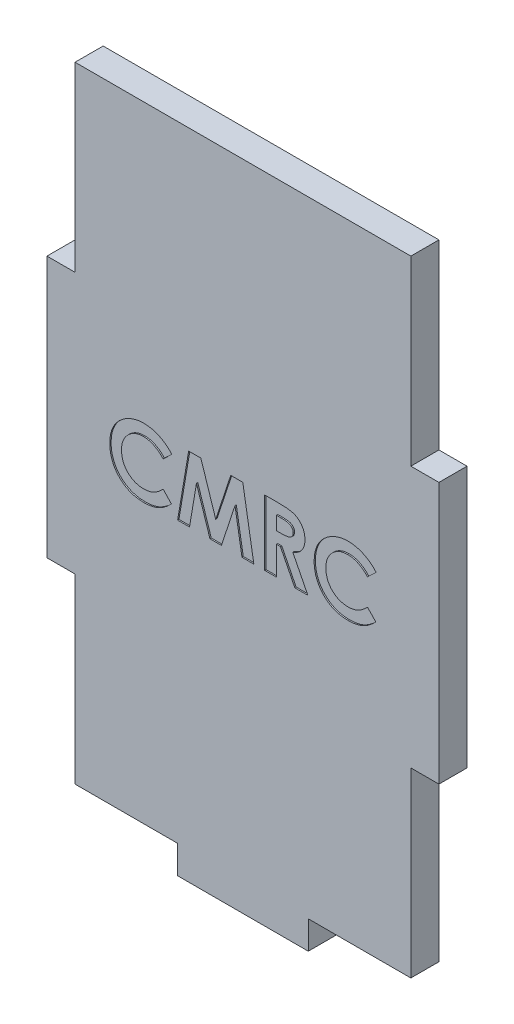
from build123d import *

# Parameters (mm, degrees)
BOSS_EXTRUDE1_DEPTH = 2.7305
CUT_EXTRUDE1_DEPTH  = 0.254


with BuildPart() as part:
    # Sketch1 → Boss-Extrude1 (new, symmetric)
    with BuildSketch(Plane.XY):
        Polygon((-32.639, -25.4), (-32.639, -60.7695), (-12.7, -60.7695), (-12.7, -66.2305), (12.7, -66.2305), (12.7, -60.7695), (32.639, -60.7695), (32.639, -25.4), (38.1, -25.4), (38.1, 25.4), (32.639, 25.4), (32.639, 60.7695), (-32.639, 60.7695), (-32.639, 25.4), (-38.1, 25.4), (-38.1, -25.4), align=None)
    extrude(amount=BOSS_EXTRUDE1_DEPTH, both=True)

    # Sketch2 → Cut-Extrude1 (cut)
    with BuildSketch(Plane.XY.offset(2.7305)):
        with BuildLine():
            Line((-13.83974359, 4.146834936), (-15.511197917, 2.549158654))
            add(Edge.make_bspline(
                [(-15.511197917, 2.549158654), (-15.65298429, 2.695766001), (-15.929937496, 2.982136081), (-16.376213337, 3.36126483), (-16.840323963, 3.677217344), (-17.313241027, 3.94331054), (-17.803470937, 4.144629007), (-18.3053453, 4.291333165), (-18.822068731, 4.380773146), (-19.171767275, 4.391006662), (-19.34765625, 4.396153846)],
                knots=[0, 0, 0, 0, 1.115251505, 2.178435587, 3.19620269, 4.182487026, 5.141301733, 6.088180966, 7.038406374, 8, 8, 8, 8], degree=3))
            add(Edge.make_bspline(
                [(-19.34765625, 4.396153846), (-19.494544919, 4.392087391), (-19.784413523, 4.384062689), (-20.210016594, 4.325233713), (-20.617127927, 4.225192477), (-21.007141129, 4.087317123), (-21.378908569, 3.908913733), (-21.733209703, 3.690120387), (-22.069171018, 3.432913099), (-22.382354658, 3.138622671), (-22.668844045, 2.817088264), (-22.921975661, 2.474011819), (-23.134013993, 2.110179305), (-23.308030404, 1.729275349), (-23.443582461, 1.329536941), (-23.54038366, 0.911233199), (-23.596370887, 0.473865956), (-23.604727356, 0.176546964), (-23.608974359, 0.025440705)],
                knots=[0, 0, 0, 0, 1.035432265, 2.043311493, 3.022114605, 3.98653278, 4.95457646, 5.923598177, 6.917315552, 7.932509744, 8.948865224, 9.949768934, 10.933144597, 11.912367597, 12.897413939, 13.903909035, 14.934704909, 16, 16, 16, 16], degree=3))
            add(Edge.make_bspline(
                [(-23.608974359, 0.025440705), (-23.607750421, -0.08061624), (-23.605338014, -0.289656657), (-23.578929956, -0.598885451), (-23.536406755, -0.898910486), (-23.474865149, -1.189277305), (-23.397906764, -1.470237542), (-23.307617056, -1.744215026), (-23.194349945, -2.007424006), (-23.068621744, -2.262921482), (-22.922401294, -2.503735887), (-22.764748675, -2.733372409), (-22.593800149, -2.95070539), (-22.408448472, -3.154846369), (-22.206085051, -3.342605078), (-21.99194023, -3.519627645), (-21.762401684, -3.681482596), (-21.522237509, -3.832231859), (-21.269372991, -3.963189027), (-21.01066893, -4.08181092), (-20.742202851, -4.178149534), (-20.46724349, -4.255807246), (-20.186773454, -4.321843532), (-19.898049487, -4.362504103), (-19.603574464, -4.393295877), (-19.404558775, -4.395197089), (-19.304407051, -4.396153846)],
                knots=[0, 0, 0, 0, 1.103660481, 2.175337485, 3.227646561, 4.255952547, 5.262355991, 6.258840057, 7.255597736, 8.242457506, 9.22035537, 10.185017736, 11.140346927, 12.096287581, 13.051739095, 14.01125915, 14.986044842, 15.97314143, 16.960198552, 17.947847494, 18.933482797, 19.925264591, 20.920966487, 21.929612487, 22.958107872, 24, 24, 24, 24], degree=3))
            add(Edge.make_bspline(
                [(-19.304407051, -4.396153846), (-19.134532516, -4.391240173), (-18.800773227, -4.381586083), (-18.31093348, -4.306092468), (-17.844165002, -4.181909743), (-17.471219221, -4.035257161), (-17.179026053, -3.890435832), (-16.956583714, -3.756483235), (-16.726560998, -3.606642547), (-16.492778386, -3.43525862), (-16.252606287, -3.244388129), (-16.010284293, -3.029850654), (-15.759608917, -2.798710606), (-15.595393964, -2.633741413), (-15.511197917, -2.549158654)],
                knots=[0, 0, 0, 0, 1.404581149, 2.759636711, 4.088442092, 5.392261763, 6.066678138, 6.783632037, 7.538459478, 8.336747902, 9.180226004, 10.074962426, 11.012997595, 12, 12, 12, 12], degree=3))
            Line((-15.511197917, -2.549158654), (-13.890625, -4.251141827))
            add(Edge.make_bspline(
                [(-13.890625, -4.251141827), (-14.004542553, -4.361125648), (-14.226885255, -4.575790546), (-14.562283048, -4.880594671), (-14.89725873, -5.15449506), (-15.223719986, -5.407433098), (-15.547014591, -5.632040086), (-15.867108262, -5.828540341), (-16.180377397, -6.001903638), (-16.493327131, -6.149206291), (-16.807904798, -6.274281543), (-17.13156825, -6.381963125), (-17.465306956, -6.47305787), (-17.81115924, -6.546559365), (-18.165899202, -6.605497641), (-18.532846737, -6.645280637), (-18.909675217, -6.672025422), (-19.165283813, -6.674428662), (-19.294230769, -6.675641026)],
                knots=[0, 0, 0, 0, 1.244526981, 2.429050516, 3.560637417, 4.644440555, 5.67424972, 6.652764056, 7.595344123, 8.486817594, 9.369275933, 10.254498637, 11.166417451, 12.086725134, 13.032340136, 13.991389299, 14.986715468, 16, 16, 16, 16], degree=3))
            add(Edge.make_bspline(
                [(-19.294230769, -6.675641026), (-19.531090356, -6.669603002), (-19.994558727, -6.657788269), (-20.673759541, -6.570249097), (-21.318982082, -6.423491216), (-21.931796056, -6.215935093), (-22.512006602, -5.950791873), (-23.059465285, -5.625738736), (-23.573289724, -5.241639296), (-24.049329227, -4.802995572), (-24.479929613, -4.318550403), (-24.860530489, -3.798389194), (-25.175363547, -3.239955544), (-25.43677622, -2.651499301), (-25.641197492, -2.030335111), (-25.785075412, -1.375791064), (-25.873803875, -0.688499162), (-25.883510895, -0.21906295), (-25.888461538, 0.020352564)],
                knots=[0, 0, 0, 0, 1.078019885, 2.10938526, 3.111377082, 4.085535484, 5.04941344, 6.010039228, 6.978205633, 7.964457913, 8.951525778, 9.924444315, 10.892603023, 11.863865945, 12.85144698, 13.863884204, 14.910567087, 16, 16, 16, 16], degree=3))
            add(Edge.make_bspline(
                [(-25.888461538, 0.020352564), (-25.886369637, 0.176497319), (-25.882223998, 0.485938061), (-25.838652957, 0.941769345), (-25.777912391, 1.38612331), (-25.681553007, 1.814386091), (-25.565401274, 2.232327176), (-25.420951332, 2.635404036), (-25.24843389, 3.024775152), (-25.053409589, 3.401092356), (-24.832780549, 3.761890367), (-24.586313691, 4.104069362), (-24.320354033, 4.430270898), (-24.028510997, 4.736167307), (-23.715025445, 5.02444442), (-23.378482027, 5.293540007), (-23.020904881, 5.547313202), (-22.641326181, 5.779219811), (-22.247120128, 5.988991665), (-21.843258699, 6.1740194), (-21.430734134, 6.328659977), (-21.011290625, 6.456928632), (-20.583156027, 6.552672113), (-20.149386257, 6.625146839), (-19.706290455, 6.665660675), (-19.408790011, 6.672293048), (-19.258613782, 6.675641026)],
                knots=[0, 0, 0, 0, 1.071919942, 2.124283339, 3.142214191, 4.149696895, 5.136002878, 6.119640489, 7.086990633, 8.058538607, 9.028339693, 9.988281803, 10.952401235, 11.916291999, 12.888973767, 13.874849856, 14.873389453, 15.898127285, 16.927174885, 17.938320013, 18.946391617, 19.950418109, 20.947802303, 21.956882652, 22.968648068, 24, 24, 24, 24], degree=3))
            add(Edge.make_bspline(
                [(-19.258613782, 6.675641026), (-19.130498061, 6.673721881), (-18.875598665, 6.669903546), (-18.496010691, 6.638073571), (-18.119458484, 6.588084917), (-17.747290216, 6.512662682), (-17.37684376, 6.423126959), (-17.012987197, 6.305892281), (-16.649980492, 6.175212138), (-16.293516868, 6.019010711), (-15.943098753, 5.848502744), (-15.606935243, 5.655055263), (-15.279382184, 5.45057281), (-14.967697955, 5.222953218), (-14.66604404, 4.980452672), (-14.375997813, 4.721939772), (-14.100104599, 4.443104348), (-13.926969337, 4.246090662), (-13.83974359, 4.146834936)],
                knots=[0, 0, 0, 0, 0.996412454, 1.982464992, 2.961075852, 3.949442424, 4.934965278, 5.923860011, 6.921385422, 7.934793307, 8.949617135, 9.951082467, 10.950285876, 11.951772932, 12.951063433, 13.960125323, 14.972308753, 16, 16, 16, 16], degree=3))
        make_face()
        Polygon((-10.555348558, 6.35), (-8.189362981, 6.35), (-5.291666667, -2.508453526), (-2.373617788, 6.35), (-0.030528846, 6.35), (2.116666667, -6.35), (-0.190805288, -6.35), (-1.546794872, 1.671454327), (-4.187540064, -6.35), (-6.411057692, -6.35), (-9.036538462, 1.671454327), (-10.389983974, -6.35), (-12.7, -6.35), align=None)
        with BuildLine():
            Line((4.233333333, 6.35), (6.889342949, 6.35))
            add(Edge.make_bspline(
                [(6.889342949, 6.35), (7.064904376, 6.349376858), (7.402558453, 6.34817838), (7.88943719, 6.329269568), (8.336702267, 6.302956405), (8.7450159, 6.262801821), (9.114203406, 6.209561695), (9.444634796, 6.146800397), (9.736300414, 6.075270442), (9.991660055, 5.986138475), (10.222109503, 5.885598967), (10.436920428, 5.770077229), (10.640831877, 5.640859631), (10.832480923, 5.49454611), (11.013533041, 5.33376881), (11.184329797, 5.158365891), (11.342457674, 4.96685001), (11.486937537, 4.760431304), (11.618619303, 4.543283559), (11.734998366, 4.315108629), (11.829638013, 4.075747835), (11.913262287, 3.828660456), (11.973494142, 3.570314331), (12.015384516, 3.303224502), (12.046055009, 3.026450785), (12.047818416, 2.838423011), (12.048717949, 2.742508013)],
                knots=[0, 0, 0, 0, 1.749336639, 3.364467119, 4.854658419, 6.213483162, 7.451590619, 8.570285859, 9.5643256, 10.440900261, 11.26203566, 12.067320669, 12.869050712, 13.665104639, 14.467235401, 15.27997916, 16.102287765, 16.939272006, 17.78853747, 18.631303466, 19.488103222, 20.351255419, 21.228522269, 22.127379805, 23.044756219, 24, 24, 24, 24], degree=3))
            add(Edge.make_bspline(
                [(12.048717949, 2.742508013), (12.046381286, 2.642394789), (12.041799516, 2.446091003), (12.017119611, 2.157736752), (11.972012498, 1.881859574), (11.903691213, 1.619267204), (11.825164771, 1.366691374), (11.720744745, 1.128792264), (11.602896425, 0.902109978), (11.462931419, 0.689851023), (11.309326662, 0.487300702), (11.130687562, 0.302219471), (10.938587187, 0.124659913), (10.722226876, -0.034256242), (10.491143992, -0.185274332), (10.240747162, -0.322136939), (9.972670561, -0.448284474), (9.784199435, -0.518633054), (9.687820513, -0.554607372)],
                knots=[0, 0, 0, 0, 1.099860209, 2.156625411, 3.176576793, 4.16617041, 5.135385252, 6.078461593, 7.016046972, 7.938469504, 8.868247731, 9.803980173, 10.76021508, 11.73834243, 12.748633912, 13.790971185, 14.870363756, 16, 16, 16, 16], degree=3))
            Line((9.687820513, -0.554607372), (12.618589744, -6.35))
            Line((12.618589744, -6.35), (10.084695513, -6.35))
            Line((10.084695513, -6.35), (7.286217949, -0.814102564))
            Line((7.286217949, -0.814102564), (6.512820513, -0.814102564))
            Line((6.512820513, -0.814102564), (6.512820513, -6.35))
            Line((6.512820513, -6.35), (4.233333333, -6.35))
            Line((4.233333333, -6.35), (4.233333333, 6.35))
        make_face()
        with BuildLine():
            Line((6.512820513, 1.465384615), (7.400701122, 1.465384615))
            add(Edge.make_bspline(
                [(7.400701122, 1.465384615), (7.509251907, 1.466607187), (7.717103335, 1.46894815), (8.016020989, 1.479806504), (8.287509507, 1.505969773), (8.532734752, 1.539026085), (8.752930675, 1.57719437), (8.946133206, 1.631891842), (9.115319303, 1.690501566), (9.258484102, 1.763338251), (9.380800817, 1.846169359), (9.486413471, 1.940267557), (9.57377028, 2.049174239), (9.645669389, 2.169929791), (9.701599079, 2.303602268), (9.742423467, 2.448724247), (9.765238264, 2.606948855), (9.767863184, 2.716145378), (9.769230769, 2.773036859)],
                knots=[0, 0, 0, 0, 1.688639943, 3.233382647, 4.650958383, 5.928841754, 7.082724185, 8.122798841, 9.049171256, 9.863274652, 10.613301712, 11.341792392, 12.054588806, 12.776240173, 13.521029143, 14.301969904, 15.115324896, 16, 16, 16, 16], degree=3))
            add(Edge.make_bspline(
                [(9.769230769, 2.773036859), (9.766645223, 2.840343634), (9.761566398, 2.97255532), (9.711168671, 3.162893789), (9.630946375, 3.339065065), (9.52098358, 3.500273162), (9.382499736, 3.641599308), (9.223578599, 3.766179432), (9.040790267, 3.864688072), (8.871542026, 3.929663322), (8.717565688, 3.968538684), (8.5786069, 3.99750826), (8.417691788, 4.018039831), (8.234698868, 4.039817216), (8.030094596, 4.053938747), (7.802763756, 4.064244651), (7.553359242, 4.068461302), (7.379500608, 4.069809291), (7.288762019, 4.070512821)],
                knots=[0, 0, 0, 0, 1.020303359, 2.004196876, 2.966617323, 3.9489082, 4.950758222, 5.960522915, 7.003732012, 8.091992268, 8.70421221, 9.413913587, 10.24622431, 11.166358409, 12.212345909, 13.359657661, 14.621978493, 16, 16, 16, 16], degree=3))
            Line((7.288762019, 4.070512821), (6.512820513, 4.070512821))
            Line((6.512820513, 4.070512821), (6.512820513, 1.465384615))
        make_face(mode=Mode.SUBTRACT)
        with BuildLine():
            Line((25.888461538, 4.146834936), (24.217007212, 2.549158654))
            add(Edge.make_bspline(
                [(24.217007212, 2.549158654), (24.075220839, 2.695766001), (23.798267632, 2.982136081), (23.351991791, 3.36126483), (22.887881165, 3.677217344), (22.414964101, 3.94331054), (21.924734191, 4.144629007), (21.422859829, 4.291333165), (20.906136397, 4.380773146), (20.556437853, 4.391006662), (20.380548878, 4.396153846)],
                knots=[0, 0, 0, 0, 1.115251505, 2.178435587, 3.19620269, 4.182487026, 5.141301733, 6.088180966, 7.038406374, 8, 8, 8, 8], degree=3))
            add(Edge.make_bspline(
                [(20.380548878, 4.396153846), (20.233660209, 4.392087391), (19.943791605, 4.384062689), (19.518188534, 4.325233713), (19.111077201, 4.225192477), (18.721063999, 4.087317123), (18.349296559, 3.908913733), (17.994995425, 3.690120387), (17.65903411, 3.432913099), (17.34585047, 3.138622671), (17.059361083, 2.817088264), (16.806229468, 2.474011819), (16.594191135, 2.110179305), (16.420174724, 1.729275349), (16.284622667, 1.329536941), (16.187821468, 0.911233199), (16.131834241, 0.473865956), (16.123477772, 0.176546964), (16.119230769, 0.025440705)],
                knots=[0, 0, 0, 0, 1.035432265, 2.043311493, 3.022114605, 3.98653278, 4.95457646, 5.923598177, 6.917315552, 7.932509744, 8.948865224, 9.949768934, 10.933144597, 11.912367597, 12.897413939, 13.903909035, 14.934704909, 16, 16, 16, 16], degree=3))
            add(Edge.make_bspline(
                [(16.119230769, 0.025440705), (16.120454707, -0.08061624), (16.122867114, -0.289656657), (16.149275172, -0.598885451), (16.191798373, -0.898910486), (16.25333998, -1.189277305), (16.330298364, -1.470237542), (16.420588072, -1.744215026), (16.533855183, -2.007424006), (16.659583385, -2.262921482), (16.805803835, -2.503735887), (16.963456454, -2.733372409), (17.13440498, -2.95070539), (17.319756656, -3.154846369), (17.522120077, -3.342605078), (17.736264898, -3.519627645), (17.965803444, -3.681482596), (18.205967619, -3.832231859), (18.458832137, -3.963189027), (18.717536198, -4.08181092), (18.986002277, -4.178149534), (19.260961638, -4.255807246), (19.541431674, -4.321843532), (19.830155641, -4.362504103), (20.124630664, -4.393295877), (20.323646353, -4.395197089), (20.423798077, -4.396153846)],
                knots=[0, 0, 0, 0, 1.103660481, 2.175337485, 3.227646561, 4.255952547, 5.262355991, 6.258840057, 7.255597736, 8.242457506, 9.22035537, 10.185017736, 11.140346927, 12.096287581, 13.051739095, 14.01125915, 14.986044842, 15.97314143, 16.960198552, 17.947847494, 18.933482797, 19.925264591, 20.920966487, 21.929612487, 22.958107872, 24, 24, 24, 24], degree=3))
            add(Edge.make_bspline(
                [(20.423798077, -4.396153846), (20.593672613, -4.391240173), (20.927431901, -4.381586083), (21.417271648, -4.306092468), (21.884040126, -4.181909743), (22.256985907, -4.035257161), (22.549179075, -3.890435832), (22.771621414, -3.756483235), (23.00164413, -3.606642547), (23.235426742, -3.43525862), (23.475598841, -3.244388129), (23.717920835, -3.029850654), (23.968596211, -2.798710606), (24.132811164, -2.633741413), (24.217007212, -2.549158654)],
                knots=[0, 0, 0, 0, 1.404581149, 2.759636711, 4.088442092, 5.392261763, 6.066678138, 6.783632037, 7.538459478, 8.336747902, 9.180226004, 10.074962426, 11.012997595, 12, 12, 12, 12], degree=3))
            Line((24.217007212, -2.549158654), (25.837580128, -4.251141827))
            add(Edge.make_bspline(
                [(25.837580128, -4.251141827), (25.723662575, -4.361125648), (25.501319873, -4.575790546), (25.16592208, -4.880594671), (24.830946398, -5.15449506), (24.504485143, -5.407433098), (24.181190537, -5.632040086), (23.861096866, -5.828540341), (23.547827731, -6.001903638), (23.234877997, -6.149206291), (22.92030033, -6.274281543), (22.596636878, -6.381963125), (22.262898172, -6.47305787), (21.917045889, -6.546559365), (21.562305926, -6.605497641), (21.195358391, -6.645280637), (20.818529911, -6.672025422), (20.562921315, -6.674428662), (20.433974359, -6.675641026)],
                knots=[0, 0, 0, 0, 1.244526981, 2.429050516, 3.560637417, 4.644440555, 5.67424972, 6.652764056, 7.595344123, 8.486817594, 9.369275933, 10.254498637, 11.166417451, 12.086725134, 13.032340136, 13.991389299, 14.986715468, 16, 16, 16, 16], degree=3))
            add(Edge.make_bspline(
                [(20.433974359, -6.675641026), (20.197114773, -6.669603002), (19.733646401, -6.657788269), (19.054445588, -6.570249097), (18.409223046, -6.423491216), (17.796409072, -6.215935093), (17.216198526, -5.950791873), (16.668739843, -5.625738736), (16.154915405, -5.241639296), (15.678875901, -4.802995572), (15.248275515, -4.318550403), (14.867674639, -3.798389194), (14.552841581, -3.239955544), (14.291428908, -2.651499301), (14.087007637, -2.030335111), (13.943129716, -1.375791064), (13.854401253, -0.688499162), (13.844694233, -0.21906295), (13.83974359, 0.020352564)],
                knots=[0, 0, 0, 0, 1.078019885, 2.10938526, 3.111377082, 4.085535484, 5.04941344, 6.010039228, 6.978205633, 7.964457913, 8.951525778, 9.924444315, 10.892603023, 11.863865945, 12.85144698, 13.863884204, 14.910567087, 16, 16, 16, 16], degree=3))
            add(Edge.make_bspline(
                [(13.83974359, 0.020352564), (13.841835492, 0.176497319), (13.84598113, 0.485938061), (13.889552171, 0.941769345), (13.950292737, 1.38612331), (14.046652121, 1.814386091), (14.162803855, 2.232327176), (14.307253796, 2.635404036), (14.479771239, 3.024775152), (14.674795539, 3.401092356), (14.895424579, 3.761890367), (15.141891437, 4.104069362), (15.407851095, 4.430270898), (15.699694131, 4.736167307), (16.013179683, 5.02444442), (16.349723101, 5.293540007), (16.707300247, 5.547313202), (17.086878947, 5.779219811), (17.481085, 5.988991665), (17.884946429, 6.1740194), (18.297470994, 6.328659977), (18.716914503, 6.456928632), (19.145049101, 6.552672113), (19.578818871, 6.625146839), (20.021914673, 6.665660675), (20.319415117, 6.672293048), (20.469591346, 6.675641026)],
                knots=[0, 0, 0, 0, 1.071919942, 2.124283339, 3.142214191, 4.149696895, 5.136002878, 6.119640489, 7.086990633, 8.058538607, 9.028339693, 9.988281803, 10.952401235, 11.916291999, 12.888973767, 13.874849856, 14.873389453, 15.898127285, 16.927174885, 17.938320013, 18.946391617, 19.950418109, 20.947802303, 21.956882652, 22.968648068, 24, 24, 24, 24], degree=3))
            add(Edge.make_bspline(
                [(20.469591346, 6.675641026), (20.597707067, 6.673721881), (20.852606463, 6.669903546), (21.232194437, 6.638073571), (21.608746644, 6.588084917), (21.980914912, 6.512662682), (22.351361368, 6.423126959), (22.715217931, 6.305892281), (23.078224636, 6.175212138), (23.43468826, 6.019010711), (23.785106375, 5.848502744), (24.121269885, 5.655055263), (24.448822944, 5.45057281), (24.760507173, 5.222953218), (25.062161088, 4.980452672), (25.352207315, 4.721939772), (25.628100529, 4.443104348), (25.801235791, 4.246090662), (25.888461538, 4.146834936)],
                knots=[0, 0, 0, 0, 0.996412454, 1.982464992, 2.961075852, 3.949442424, 4.934965278, 5.923860011, 6.921385422, 7.934793307, 8.949617135, 9.951082467, 10.950285876, 11.951772932, 12.951063433, 13.960125323, 14.972308753, 16, 16, 16, 16], degree=3))
        make_face()
    extrude(amount=-CUT_EXTRUDE1_DEPTH, mode=Mode.SUBTRACT)


solid = part.part
